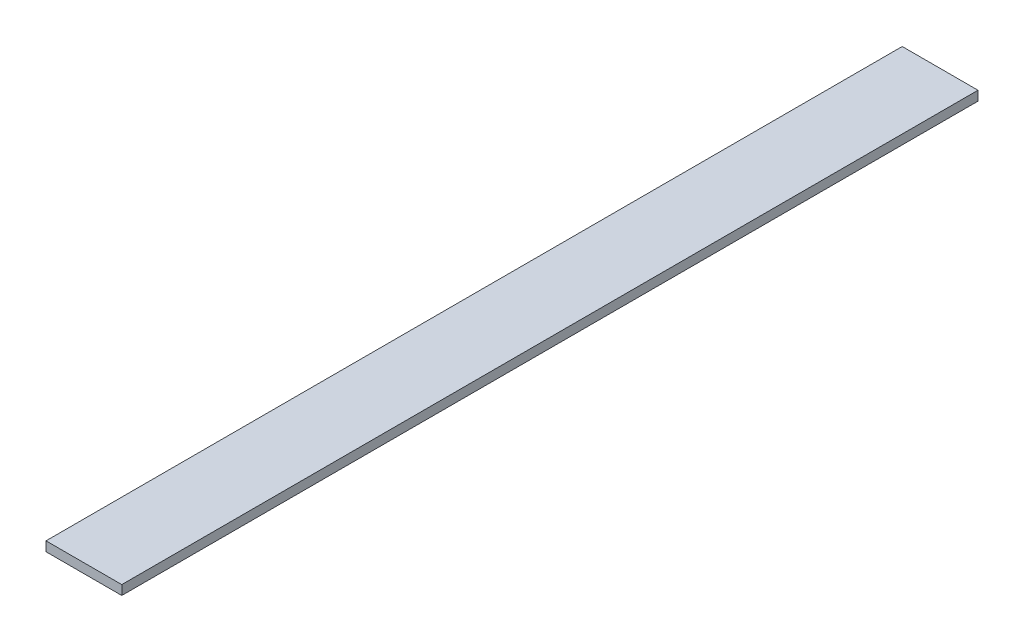
from build123d import *

# Parameters (mm, degrees)
SKETCH_1_W      = 40
SKETCH_1_H      = 5
EXTRUDE_1_DEPTH = 452


with BuildPart() as part:
    # Эскиз1 → Бобышка-Вытянуть1 (new body)
    with BuildSketch(Plane.XY):
        with Locations((20, -2.5)):
            Rectangle(SKETCH_1_W, SKETCH_1_H)
    extrude(amount=EXTRUDE_1_DEPTH)


solid = part.part
